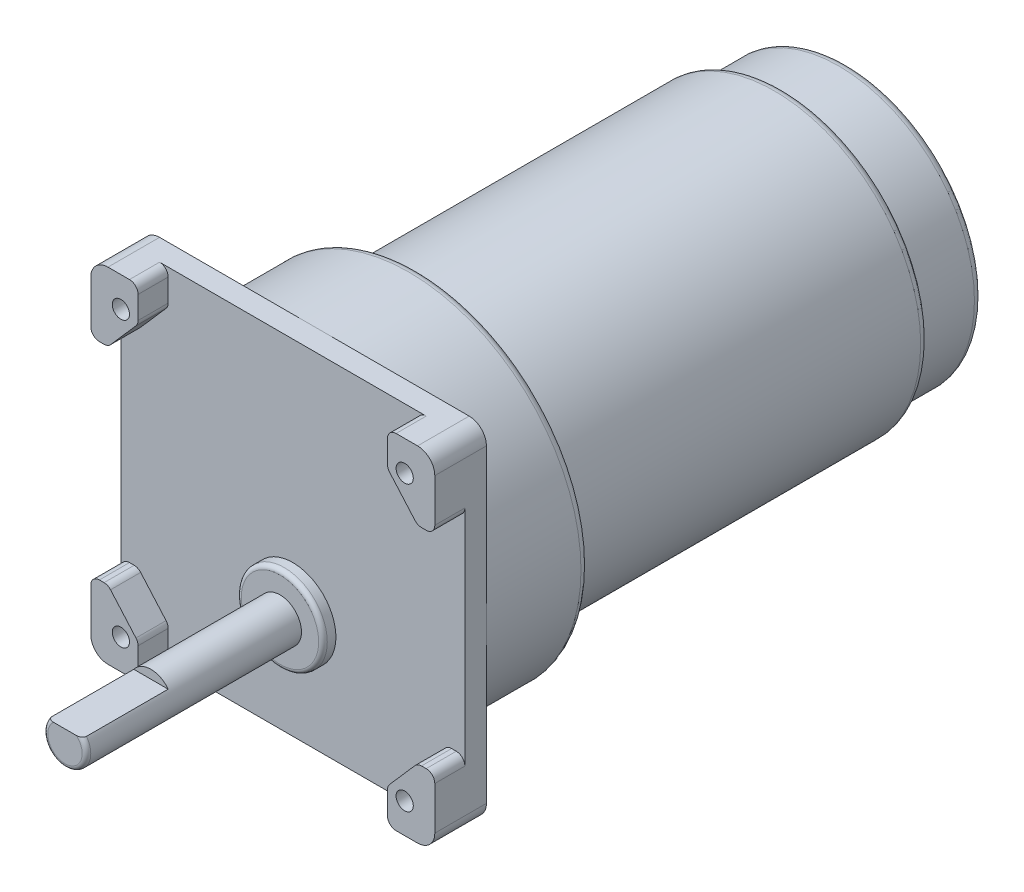
from build123d import *

# Parameters (mm, degrees)
SKETCH1_R               = 40
BOSS_EXTRUDE1_DEPTH     = 24
SKETCH2_W               = 80
SKETCH2_H               = 80
SKETCH2_R               = 2
BOSS_EXTRUDE2_DEPTH     = 5
FILLET1_R               = 4
SKETCH3_R               = 34
BOSS_EXTRUDE3_DEPTH     = 100
SKETCH4_R               = 10
BOSS_EXTRUDE4_DEPTH     = 3
SKETCH5_R               = 5
BOSS_EXTRUDE5_DEPTH     = 50
FILLET3_R               = 1
FILLET4_R               = 1
SKETCH6_W               = 26.979088542
SKETCH6_H               = 2
CUT_EXTRUDE1_DEPTH      = 1
CUT_EXTRUDE1_DEPTH_BACK = 81
SKETCH8_R               = 2
BOSS_EXTRUDE6_DEPTH     = 7
FILLET5_R               = 2
SKETCH10_R              = 34
SKETCH10_R_2            = 31.5
CUT_EXTRUDE3_DEPTH      = 15
FILLET6_R               = 2
FILLET7_R               = 2
FILLET8_R               = 2


with BuildPart() as part:
    # Sketch1 → Boss-Extrude1 (new body)
    with BuildSketch(Plane.XY):
        Circle(SKETCH1_R)
    extrude(amount=BOSS_EXTRUDE1_DEPTH)

    # Sketch2 → Boss-Extrude2 (add)
    with BuildSketch(Plane.XY.offset(24)):
        Rectangle(SKETCH2_W, SKETCH2_H)
        with Locations((33, -33)):
            Circle(SKETCH2_R, mode=Mode.SUBTRACT)
        with Locations((-33, 33)):
            Circle(SKETCH2_R, mode=Mode.SUBTRACT)
        with Locations((33, 33)):
            Circle(SKETCH2_R, mode=Mode.SUBTRACT)
        with Locations((-33, -33)):
            Circle(SKETCH2_R, mode=Mode.SUBTRACT)
    extrude(amount=BOSS_EXTRUDE2_DEPTH)

    # Fillet1
    fillet1_edges = [part.edges().sort_by_distance(p)[0] for p in [
        (40, 40, 26.5),
        (-40, 40, 26.5),
        (-40, -40, 26.5),
        (40, -40, 26.5),
    ]]
    fillet(fillet1_edges, radius=FILLET1_R)

    # Sketch3 → Boss-Extrude3 (add)
    with BuildSketch(Plane(origin=(0, 0, 0), x_dir=(-1, 0, 0), z_dir=(0, 0, -1))):
        Circle(SKETCH3_R)
    extrude(amount=BOSS_EXTRUDE3_DEPTH)

    # Sketch4 → Boss-Extrude4 (add)
    with BuildSketch(Plane.XY.offset(29)):
        with Locations((0, -15)):
            Circle(SKETCH4_R)
    extrude(amount=BOSS_EXTRUDE4_DEPTH)

    # Sketch5 → Boss-Extrude5 (add)
    with BuildSketch(Plane.XY.offset(32)):
        with Locations((0, -15)):
            Circle(SKETCH5_R)
    extrude(amount=BOSS_EXTRUDE5_DEPTH)

    # Fillet3
    fillet3_edges = [part.edges().sort_by_distance(p)[0] for p in [
        (-10, -15, 32),
    ]]
    fillet(fillet3_edges, radius=FILLET3_R)

    # Fillet4
    fillet4_edges = [part.edges().sort_by_distance(p)[0] for p in [
        (-5, -15, 82),
    ]]
    fillet(fillet4_edges, radius=FILLET4_R)

    # Sketch6 → Cut-Extrude1 (cut, two sides)
    with BuildSketch(Plane.ZY.offset(40)) as cut_extrude1_sk:
        with Locations((75.489544271, -11)):
            Rectangle(SKETCH6_W, SKETCH6_H)
    extrude(amount=CUT_EXTRUDE1_DEPTH, mode=Mode.SUBTRACT)
    extrude(cut_extrude1_sk.sketch, amount=-CUT_EXTRUDE1_DEPTH_BACK, mode=Mode.SUBTRACT)

    # Sketch8 → Boss-Extrude6 (add)
    with BuildSketch(Plane.XY.offset(29)):
        with BuildLine():
            Line((-36, -24), (-40, -24))
            Line((-40, -24), (-40, -36))
            ThreePointArc((-40, -36), (-38.828427125, -38.828427125), (-36, -40))
            Line((-36, -40), (-29, -40))
            Line((-29, -40), (-29, -32))
            Line((-29, -32), (-36, -24))
        make_face()
        with Locations((-33, -33)):
            Circle(SKETCH8_R, mode=Mode.SUBTRACT)
        with BuildLine():
            Line((29, -32), (29, -40))
            Line((29, -40), (36, -40))
            ThreePointArc((36, -40), (38.828427125, -38.828427125), (40, -36))
            Line((40, -36), (40, -24))
            Line((40, -24), (36, -24))
            Line((36, -24), (29, -32))
        make_face()
        with Locations((33, -33)):
            Circle(SKETCH8_R, mode=Mode.SUBTRACT)
        with BuildLine():
            Line((-40, 36), (-40, 24))
            Line((-40, 24), (-36, 24))
            Line((-36, 24), (-29, 32))
            Line((-29, 32), (-29, 40))
            Line((-29, 40), (-36, 40))
            ThreePointArc((-36, 40), (-38.828427125, 38.828427125), (-40, 36))
        make_face()
        with Locations((-33, 33)):
            Circle(SKETCH8_R, mode=Mode.SUBTRACT)
        with BuildLine():
            Line((36, 40), (29, 40))
            Line((29, 40), (29, 32))
            Line((29, 32), (36, 24))
            Line((36, 24), (40, 24))
            Line((40, 24), (40, 36))
            ThreePointArc((40, 36), (38.828427125, 38.828427125), (36, 40))
        make_face()
        with Locations((33, 33)):
            Circle(SKETCH8_R, mode=Mode.SUBTRACT)
    extrude(amount=BOSS_EXTRUDE6_DEPTH)

    # Fillet5
    fillet5_edges = [part.edges().sort_by_distance(p)[0] for p in [
        (-36, -24, 32.5),
        (-40, -24, 32.5),
        (-29, -40, 32.5),
        (-29, -32, 32.5),
        (36, -24, 32.5),
        (29, -32, 32.5),
        (29, -40, 32.5),
        (40, -24, 32.5),
        (-36, 24, 32.5),
        (-29, 32, 32.5),
        (-29, 40, 32.5),
        (-40, 24, 32.5),
        (36, 24, 32.5),
        (40, 24, 32.5),
        (29, 40, 32.5),
        (29, 32, 32.5),
    ]]
    fillet(fillet5_edges, radius=FILLET5_R)

    # Sketch10 → Cut-Extrude3 (cut)
    with BuildSketch(Plane(origin=(0, 0, -100), x_dir=(-1, 0, 0), z_dir=(0, 0, -1))):
        Circle(SKETCH10_R)
        Circle(SKETCH10_R_2, mode=Mode.SUBTRACT)
    extrude(amount=-CUT_EXTRUDE3_DEPTH, mode=Mode.SUBTRACT)

    # Fillet6
    fillet6_edges = [part.edges().sort_by_distance(p)[0] for p in [
        (31.5, 0, -100),
    ]]
    fillet(fillet6_edges, radius=FILLET6_R)

    # Fillet7
    fillet7_edges = [part.edges().sort_by_distance(p)[0] for p in [
        (34, 0, -85),
    ]]
    fillet(fillet7_edges, radius=FILLET7_R)

    # Fillet8
    fillet8_edges = [part.edges().sort_by_distance(p)[0] for p in [
        (-40, 0, 0),
    ]]
    fillet(fillet8_edges, radius=FILLET8_R)


solid = part.part
